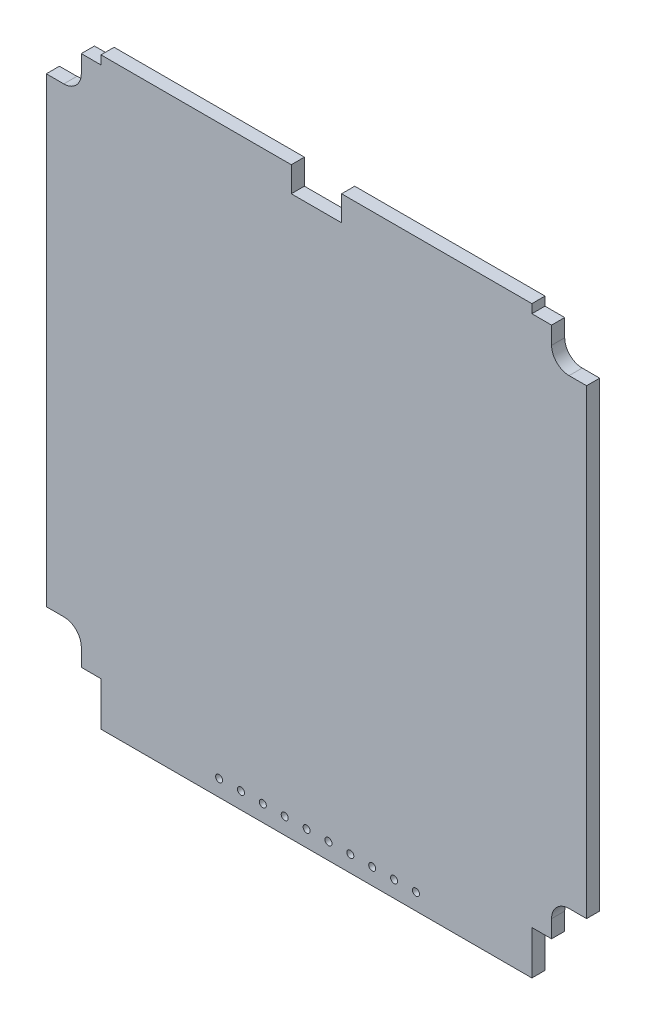
from build123d import *

# Parameters (mm, degrees)
SKETCH1_W            = 62.738
SKETCH1_H            = 67.818
PCB_DEPTH            = 1.524
CUT1_DEPTH           = 47.21857871
MIRROR3_COPY_1_DEPTH = 47.21857871
SKETCH4_W            = 5.842
SKETCH4_H            = 2.921
CUTOUT_DEPTH         = 1.524
SKETCH3_R            = 0.4064
HOLES_DEPTH          = 47.21857871
SKETCH5_R            = 0.4064
SOLDER_PAD_DEPTH     = 0.0254
LPATTERN1_COUNT      = 10
LPATTERN1_PITCH      = 2.54


with BuildPart() as part:
    # Sketch1 → PCB (new body)
    with BuildSketch(Plane.XY):
        Rectangle(SKETCH1_W, SKETCH1_H)
    extrude(amount=PCB_DEPTH)

    # Sketch2 → cut1 (cut, through all)
    with BuildSketch(Plane.XY.offset(1.524)):
        with BuildLine():
            Line((-31.369, 28.829), (-29.337, 28.829))
            ThreePointArc((-29.337, 28.829), (-27.900159021, 29.424159021), (-27.305, 30.861))
            Line((-27.305, 30.861), (-27.305, 32.893))
            Line((-27.305, 32.893), (-25.019, 32.893))
            Line((-25.019, 32.893), (-25.019, 40.259))
            Line((-25.019, 40.259), (-31.369, 40.259))
            Line((-31.369, 40.259), (-31.369, 28.829))
        make_face()
    cut1 = extrude(amount=-CUT1_DEPTH, mode=Mode.SUBTRACT)

    # Mirror1: cut1 across plane
    add(cut1.mirror(Plane(origin=(0, 0, 0), x_dir=(0, 0, 1), z_dir=(1, 0, 0))), mode=Mode.SUBTRACT)

    # Mirror3: cut1 across plane
    add(cut1.mirror(Plane(origin=(0, 2.032, 0), x_dir=(0, 0, 1), z_dir=(0, -1, 0))), mode=Mode.SUBTRACT)

    # Mirror3 copy 1 sketch → Mirror3 copy 1 (cut, through all)
    with BuildSketch(Plane(origin=(0, 4.064, 1.524), x_dir=(-1, 0, 0), z_dir=(0, 0, 1))):
        with BuildLine():
            Line((-31.369, 28.829), (-29.337, 28.829))
            ThreePointArc((-29.337, 28.829), (-27.900159021, 29.424159021), (-27.305, 30.861))
            Line((-27.305, 30.861), (-27.305, 32.893))
            Line((-27.305, 32.893), (-25.019, 32.893))
            Line((-25.019, 32.893), (-25.019, 40.259))
            Line((-25.019, 40.259), (-31.369, 40.259))
            Line((-31.369, 40.259), (-31.369, 28.829))
        make_face()
    extrude(amount=-MIRROR3_COPY_1_DEPTH, mode=Mode.SUBTRACT)

    # Sketch4 → cutout (cut)
    with BuildSketch(Plane(origin=(0, 0, 0), x_dir=(-1, 0, 0), z_dir=(0, 0, -1))):
        with Locations((0, 32.4485)):
            Rectangle(SKETCH4_W, SKETCH4_H)
    extrude(amount=-CUTOUT_DEPTH, mode=Mode.SUBTRACT)

    # Sketch3 → holes (cut, through all)
    with BuildSketch(Plane.XY.offset(1.524)):
        with Locations((-11.303, -32.004)):
            Circle(SKETCH3_R)
        with Locations((-8.763, -32.004)):
            Circle(SKETCH3_R)
        with Locations((-6.223, -32.004)):
            Circle(SKETCH3_R)
        with Locations((-3.683, -32.004)):
            Circle(SKETCH3_R)
        with Locations((-1.143, -32.004)):
            Circle(SKETCH3_R)
        with Locations((1.397, -32.004)):
            Circle(SKETCH3_R)
        with Locations((3.937, -32.004)):
            Circle(SKETCH3_R)
        with Locations((6.477, -32.004)):
            Circle(SKETCH3_R)
        with Locations((9.017, -32.004)):
            Circle(SKETCH3_R)
        with Locations((11.557, -32.004)):
            Circle(SKETCH3_R)
    extrude(amount=-HOLES_DEPTH, mode=Mode.SUBTRACT)

    # Sketch5 → solder pad (add)
    with BuildSketch(Plane(origin=(0, 0, 0), x_dir=(-1, 0, 0), z_dir=(0, 0, -1))):
        with BuildLine():
            Line((-12.192, -31.369), (-12.192, -32.639))
            ThreePointArc((-12.192, -32.639), (-11.557, -33.274), (-10.922, -32.639))
            Line((-10.922, -32.639), (-10.922, -31.369))
            ThreePointArc((-10.922, -31.369), (-11.557, -30.734), (-12.192, -31.369))
        make_face()
        with Locations(Location((-11.557, -32.004, 0), (0, 0, 180))):
            Circle(SKETCH5_R, mode=Mode.SUBTRACT)
    solder_pad = extrude(amount=SOLDER_PAD_DEPTH)

    # LPattern1: solder pad ×10
    with Locations(*[(-i * LPATTERN1_PITCH, 0, 0) for i in range(1, LPATTERN1_COUNT)]):
        add(solder_pad)


solid = part.part
